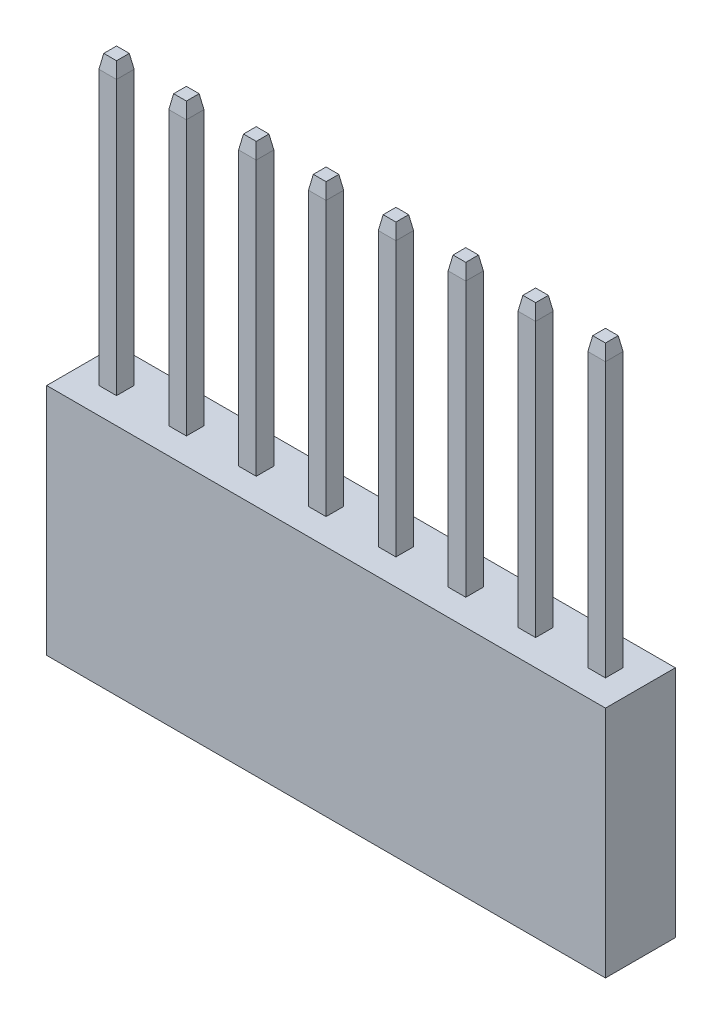
from build123d import *
from OCP.BRepFilletAPI import BRepFilletAPI_MakeChamfer

# Parameters (mm, degrees)
SKETCH1_W                   = 2.54
SKETCH1_H                   = 2.54
BOSS_EXTRUDE1_DEPTH         = 8.5
SKETCH2_W                   = 0.64
SKETCH2_H                   = 0.64
BOSS_EXTRUDE2_DEPTH         = 18.9595482
CHAMFER1_SIZE               = 0.5
CHAMFER1_SIZE2              = 0.08816349
SKETCH3_W                   = 0.64
SKETCH3_H                   = 0.64
CUT_EXTRUDE1_DEPTH          = 6
CHAMFER2_SIZE               = 0.64
LPATTERN1_COUNT             = 8
LPATTERN1_PITCH             = 2.54
CHAMFER1_OF_LPATTERN1_SIZE  = 0.5
CHAMFER1_OF_LPATTERN1_SIZE2 = 0.08816349
CHAMFER2_OF_LPATTERN1_SIZE  = 0.64


with BuildPart() as part:
    # Sketch1 → Boss-Extrude1 (new body)
    with BuildSketch(Plane(origin=(0, 0, 0), x_dir=(1, 0, 0), z_dir=(0, 1, 0))):
        Rectangle(SKETCH1_W, SKETCH1_H)
    boss_extrude1 = extrude(amount=BOSS_EXTRUDE1_DEPTH)

    # Sketch2 → Boss-Extrude2 (add)
    with BuildSketch(Plane(origin=(0, 0, 0), x_dir=(1, 0, 0), z_dir=(0, 1, 0))):
        Rectangle(SKETCH2_W, SKETCH2_H)
    boss_extrude2 = extrude(amount=BOSS_EXTRUDE2_DEPTH)

    # Chamfer1: one chamfer whose edges measure the first distance from different faces: ONE call of the kernel's chamfer builder (chamfer() names one face for all edges)
    chamfer1_edges_1 = [part.edges().sort_by_distance(p)[0] for p in [
        (-0.32, 18.9595482, 0),
    ]]
    chamfer1_side_1 = [part.faces().sort_by_distance(p)[0] for p in [
        (-0.32, 13.7297741, 0),
    ]]
    chamfer1_edges_2 = [part.edges().sort_by_distance(p)[0] for p in [
        (0, 18.9595482, 0.32),
    ]]
    chamfer1_side_2 = [part.faces().sort_by_distance(p)[0] for p in [
        (0, 13.7297741, 0.32),
    ]]
    chamfer1_edges_3 = [part.edges().sort_by_distance(p)[0] for p in [
        (0.32, 18.9595482, 0),
    ]]
    chamfer1_side_3 = [part.faces().sort_by_distance(p)[0] for p in [
        (0.32, 13.7297741, 0),
    ]]
    chamfer1_edges_4 = [part.edges().sort_by_distance(p)[0] for p in [
        (0, 18.9595482, -0.32),
    ]]
    chamfer1_side_4 = [part.faces().sort_by_distance(p)[0] for p in [
        (0, 13.7297741, -0.32),
    ]]
    chamfer1 = BRepFilletAPI_MakeChamfer(part.part.solid().wrapped)
    for e in chamfer1_edges_1:
        chamfer1.Add(CHAMFER1_SIZE, CHAMFER1_SIZE2, e.wrapped, chamfer1_side_1[0].wrapped)  # the first distance lies on this face
    for e in chamfer1_edges_2:
        chamfer1.Add(CHAMFER1_SIZE, CHAMFER1_SIZE2, e.wrapped, chamfer1_side_2[0].wrapped)  # the first distance lies on this face
    for e in chamfer1_edges_3:
        chamfer1.Add(CHAMFER1_SIZE, CHAMFER1_SIZE2, e.wrapped, chamfer1_side_3[0].wrapped)  # the first distance lies on this face
    for e in chamfer1_edges_4:
        chamfer1.Add(CHAMFER1_SIZE, CHAMFER1_SIZE2, e.wrapped, chamfer1_side_4[0].wrapped)  # the first distance lies on this face
    add(Compound.cast(chamfer1.Shape()), mode=Mode.REPLACE)

    # Sketch3 → Cut-Extrude1 (cut)
    with BuildSketch(Plane.XZ):
        Rectangle(SKETCH3_W, SKETCH3_H)
    cut_extrude1 = extrude(amount=-CUT_EXTRUDE1_DEPTH, mode=Mode.SUBTRACT)

    # Chamfer2
    chamfer2_edges = [part.edges().sort_by_distance(p)[0] for p in [
        (-0.32, 0, 0),
        (0, 0, -0.32),
        (0.32, 0, 0),
        (0, 0, 0.32),
    ]]
    chamfer(chamfer2_edges, length=CHAMFER2_SIZE)

    # LPattern1: Boss-Extrude1, Boss-Extrude2, Cut-Extrude1 ×8
    with Locations(*[(-i * LPATTERN1_PITCH, 0, 0) for i in range(1, LPATTERN1_COUNT)]):
        add(boss_extrude1)
        add(boss_extrude2)
        add(cut_extrude1, mode=Mode.SUBTRACT)

    # Chamfer1 of LPattern1: one chamfer whose edges measure the first distance from different faces: ONE call of the kernel's chamfer builder (chamfer() names one face for all edges)
    chamfer1_of_lpattern1_edges_1 = [part.edges().sort_by_distance(p)[0] for p in [
        (-2.86, 18.9595482, 0),
    ]]
    chamfer1_of_lpattern1_side_1 = [part.faces().sort_by_distance(p)[0] for p in [
        (-2.86, 13.7297741, 0),
    ]]
    chamfer1_of_lpattern1_edges_2 = [part.edges().sort_by_distance(p)[0] for p in [
        (-2.54, 18.9595482, 0.32),
    ]]
    chamfer1_of_lpattern1_side_2 = [part.faces().sort_by_distance(p)[0] for p in [
        (-2.54, 13.7297741, 0.32),
    ]]
    chamfer1_of_lpattern1_edges_3 = [part.edges().sort_by_distance(p)[0] for p in [
        (-2.22, 18.9595482, 0),
    ]]
    chamfer1_of_lpattern1_side_3 = [part.faces().sort_by_distance(p)[0] for p in [
        (-2.22, 13.7297741, 0),
    ]]
    chamfer1_of_lpattern1_edges_4 = [part.edges().sort_by_distance(p)[0] for p in [
        (-2.54, 18.9595482, -0.32),
    ]]
    chamfer1_of_lpattern1_side_4 = [part.faces().sort_by_distance(p)[0] for p in [
        (-2.54, 13.7297741, -0.32),
    ]]
    chamfer1_of_lpattern1_edges_5 = [part.edges().sort_by_distance(p)[0] for p in [
        (-5.4, 18.9595482, 0),
    ]]
    chamfer1_of_lpattern1_side_5 = [part.faces().sort_by_distance(p)[0] for p in [
        (-5.4, 13.7297741, 0),
    ]]
    chamfer1_of_lpattern1_edges_6 = [part.edges().sort_by_distance(p)[0] for p in [
        (-5.08, 18.9595482, 0.32),
    ]]
    chamfer1_of_lpattern1_side_6 = [part.faces().sort_by_distance(p)[0] for p in [
        (-5.08, 13.7297741, 0.32),
    ]]
    chamfer1_of_lpattern1_edges_7 = [part.edges().sort_by_distance(p)[0] for p in [
        (-4.76, 18.9595482, 0),
    ]]
    chamfer1_of_lpattern1_side_7 = [part.faces().sort_by_distance(p)[0] for p in [
        (-4.76, 13.7297741, 0),
    ]]
    chamfer1_of_lpattern1_edges_8 = [part.edges().sort_by_distance(p)[0] for p in [
        (-5.08, 18.9595482, -0.32),
    ]]
    chamfer1_of_lpattern1_side_8 = [part.faces().sort_by_distance(p)[0] for p in [
        (-5.08, 13.7297741, -0.32),
    ]]
    chamfer1_of_lpattern1_edges_9 = [part.edges().sort_by_distance(p)[0] for p in [
        (-7.94, 18.9595482, 0),
    ]]
    chamfer1_of_lpattern1_side_9 = [part.faces().sort_by_distance(p)[0] for p in [
        (-7.94, 13.7297741, 0),
    ]]
    chamfer1_of_lpattern1_edges_10 = [part.edges().sort_by_distance(p)[0] for p in [
        (-7.62, 18.9595482, 0.32),
    ]]
    chamfer1_of_lpattern1_side_10 = [part.faces().sort_by_distance(p)[0] for p in [
        (-7.62, 13.7297741, 0.32),
    ]]
    chamfer1_of_lpattern1_edges_11 = [part.edges().sort_by_distance(p)[0] for p in [
        (-7.3, 18.9595482, 0),
    ]]
    chamfer1_of_lpattern1_side_11 = [part.faces().sort_by_distance(p)[0] for p in [
        (-7.3, 13.7297741, 0),
    ]]
    chamfer1_of_lpattern1_edges_12 = [part.edges().sort_by_distance(p)[0] for p in [
        (-7.62, 18.9595482, -0.32),
    ]]
    chamfer1_of_lpattern1_side_12 = [part.faces().sort_by_distance(p)[0] for p in [
        (-7.62, 13.7297741, -0.32),
    ]]
    chamfer1_of_lpattern1_edges_13 = [part.edges().sort_by_distance(p)[0] for p in [
        (-10.48, 18.9595482, 0),
    ]]
    chamfer1_of_lpattern1_side_13 = [part.faces().sort_by_distance(p)[0] for p in [
        (-10.48, 13.7297741, 0),
    ]]
    chamfer1_of_lpattern1_edges_14 = [part.edges().sort_by_distance(p)[0] for p in [
        (-10.16, 18.9595482, 0.32),
    ]]
    chamfer1_of_lpattern1_side_14 = [part.faces().sort_by_distance(p)[0] for p in [
        (-10.16, 13.7297741, 0.32),
    ]]
    chamfer1_of_lpattern1_edges_15 = [part.edges().sort_by_distance(p)[0] for p in [
        (-9.84, 18.9595482, 0),
    ]]
    chamfer1_of_lpattern1_side_15 = [part.faces().sort_by_distance(p)[0] for p in [
        (-9.84, 13.7297741, 0),
    ]]
    chamfer1_of_lpattern1_edges_16 = [part.edges().sort_by_distance(p)[0] for p in [
        (-10.16, 18.9595482, -0.32),
    ]]
    chamfer1_of_lpattern1_side_16 = [part.faces().sort_by_distance(p)[0] for p in [
        (-10.16, 13.7297741, -0.32),
    ]]
    chamfer1_of_lpattern1_edges_17 = [part.edges().sort_by_distance(p)[0] for p in [
        (-13.02, 18.9595482, 0),
    ]]
    chamfer1_of_lpattern1_side_17 = [part.faces().sort_by_distance(p)[0] for p in [
        (-13.02, 13.7297741, 0),
    ]]
    chamfer1_of_lpattern1_edges_18 = [part.edges().sort_by_distance(p)[0] for p in [
        (-12.7, 18.9595482, 0.32),
    ]]
    chamfer1_of_lpattern1_side_18 = [part.faces().sort_by_distance(p)[0] for p in [
        (-12.7, 13.7297741, 0.32),
    ]]
    chamfer1_of_lpattern1_edges_19 = [part.edges().sort_by_distance(p)[0] for p in [
        (-12.38, 18.9595482, 0),
    ]]
    chamfer1_of_lpattern1_side_19 = [part.faces().sort_by_distance(p)[0] for p in [
        (-12.38, 13.7297741, 0),
    ]]
    chamfer1_of_lpattern1_edges_20 = [part.edges().sort_by_distance(p)[0] for p in [
        (-12.7, 18.9595482, -0.32),
    ]]
    chamfer1_of_lpattern1_side_20 = [part.faces().sort_by_distance(p)[0] for p in [
        (-12.7, 13.7297741, -0.32),
    ]]
    chamfer1_of_lpattern1_edges_21 = [part.edges().sort_by_distance(p)[0] for p in [
        (-15.56, 18.9595482, 0),
    ]]
    chamfer1_of_lpattern1_side_21 = [part.faces().sort_by_distance(p)[0] for p in [
        (-15.56, 13.7297741, 0),
    ]]
    chamfer1_of_lpattern1_edges_22 = [part.edges().sort_by_distance(p)[0] for p in [
        (-15.24, 18.9595482, 0.32),
    ]]
    chamfer1_of_lpattern1_side_22 = [part.faces().sort_by_distance(p)[0] for p in [
        (-15.24, 13.7297741, 0.32),
    ]]
    chamfer1_of_lpattern1_edges_23 = [part.edges().sort_by_distance(p)[0] for p in [
        (-14.92, 18.9595482, 0),
    ]]
    chamfer1_of_lpattern1_side_23 = [part.faces().sort_by_distance(p)[0] for p in [
        (-14.92, 13.7297741, 0),
    ]]
    chamfer1_of_lpattern1_edges_24 = [part.edges().sort_by_distance(p)[0] for p in [
        (-15.24, 18.9595482, -0.32),
    ]]
    chamfer1_of_lpattern1_side_24 = [part.faces().sort_by_distance(p)[0] for p in [
        (-15.24, 13.7297741, -0.32),
    ]]
    chamfer1_of_lpattern1_edges_25 = [part.edges().sort_by_distance(p)[0] for p in [
        (-18.1, 18.9595482, 0),
    ]]
    chamfer1_of_lpattern1_side_25 = [part.faces().sort_by_distance(p)[0] for p in [
        (-18.1, 13.7297741, 0),
    ]]
    chamfer1_of_lpattern1_edges_26 = [part.edges().sort_by_distance(p)[0] for p in [
        (-17.78, 18.9595482, 0.32),
    ]]
    chamfer1_of_lpattern1_side_26 = [part.faces().sort_by_distance(p)[0] for p in [
        (-17.78, 13.7297741, 0.32),
    ]]
    chamfer1_of_lpattern1_edges_27 = [part.edges().sort_by_distance(p)[0] for p in [
        (-17.46, 18.9595482, 0),
    ]]
    chamfer1_of_lpattern1_side_27 = [part.faces().sort_by_distance(p)[0] for p in [
        (-17.46, 13.7297741, 0),
    ]]
    chamfer1_of_lpattern1_edges_28 = [part.edges().sort_by_distance(p)[0] for p in [
        (-17.78, 18.9595482, -0.32),
    ]]
    chamfer1_of_lpattern1_side_28 = [part.faces().sort_by_distance(p)[0] for p in [
        (-17.78, 13.7297741, -0.32),
    ]]
    chamfer1_of_lpattern1 = BRepFilletAPI_MakeChamfer(part.part.solid().wrapped)
    for e in chamfer1_of_lpattern1_edges_1:
        chamfer1_of_lpattern1.Add(CHAMFER1_OF_LPATTERN1_SIZE, CHAMFER1_OF_LPATTERN1_SIZE2, e.wrapped, chamfer1_of_lpattern1_side_1[0].wrapped)  # the first distance lies on this face
    for e in chamfer1_of_lpattern1_edges_2:
        chamfer1_of_lpattern1.Add(CHAMFER1_OF_LPATTERN1_SIZE, CHAMFER1_OF_LPATTERN1_SIZE2, e.wrapped, chamfer1_of_lpattern1_side_2[0].wrapped)  # the first distance lies on this face
    for e in chamfer1_of_lpattern1_edges_3:
        chamfer1_of_lpattern1.Add(CHAMFER1_OF_LPATTERN1_SIZE, CHAMFER1_OF_LPATTERN1_SIZE2, e.wrapped, chamfer1_of_lpattern1_side_3[0].wrapped)  # the first distance lies on this face
    for e in chamfer1_of_lpattern1_edges_4:
        chamfer1_of_lpattern1.Add(CHAMFER1_OF_LPATTERN1_SIZE, CHAMFER1_OF_LPATTERN1_SIZE2, e.wrapped, chamfer1_of_lpattern1_side_4[0].wrapped)  # the first distance lies on this face
    for e in chamfer1_of_lpattern1_edges_5:
        chamfer1_of_lpattern1.Add(CHAMFER1_OF_LPATTERN1_SIZE, CHAMFER1_OF_LPATTERN1_SIZE2, e.wrapped, chamfer1_of_lpattern1_side_5[0].wrapped)  # the first distance lies on this face
    for e in chamfer1_of_lpattern1_edges_6:
        chamfer1_of_lpattern1.Add(CHAMFER1_OF_LPATTERN1_SIZE, CHAMFER1_OF_LPATTERN1_SIZE2, e.wrapped, chamfer1_of_lpattern1_side_6[0].wrapped)  # the first distance lies on this face
    for e in chamfer1_of_lpattern1_edges_7:
        chamfer1_of_lpattern1.Add(CHAMFER1_OF_LPATTERN1_SIZE, CHAMFER1_OF_LPATTERN1_SIZE2, e.wrapped, chamfer1_of_lpattern1_side_7[0].wrapped)  # the first distance lies on this face
    for e in chamfer1_of_lpattern1_edges_8:
        chamfer1_of_lpattern1.Add(CHAMFER1_OF_LPATTERN1_SIZE, CHAMFER1_OF_LPATTERN1_SIZE2, e.wrapped, chamfer1_of_lpattern1_side_8[0].wrapped)  # the first distance lies on this face
    for e in chamfer1_of_lpattern1_edges_9:
        chamfer1_of_lpattern1.Add(CHAMFER1_OF_LPATTERN1_SIZE, CHAMFER1_OF_LPATTERN1_SIZE2, e.wrapped, chamfer1_of_lpattern1_side_9[0].wrapped)  # the first distance lies on this face
    for e in chamfer1_of_lpattern1_edges_10:
        chamfer1_of_lpattern1.Add(CHAMFER1_OF_LPATTERN1_SIZE, CHAMFER1_OF_LPATTERN1_SIZE2, e.wrapped, chamfer1_of_lpattern1_side_10[0].wrapped)  # the first distance lies on this face
    for e in chamfer1_of_lpattern1_edges_11:
        chamfer1_of_lpattern1.Add(CHAMFER1_OF_LPATTERN1_SIZE, CHAMFER1_OF_LPATTERN1_SIZE2, e.wrapped, chamfer1_of_lpattern1_side_11[0].wrapped)  # the first distance lies on this face
    for e in chamfer1_of_lpattern1_edges_12:
        chamfer1_of_lpattern1.Add(CHAMFER1_OF_LPATTERN1_SIZE, CHAMFER1_OF_LPATTERN1_SIZE2, e.wrapped, chamfer1_of_lpattern1_side_12[0].wrapped)  # the first distance lies on this face
    for e in chamfer1_of_lpattern1_edges_13:
        chamfer1_of_lpattern1.Add(CHAMFER1_OF_LPATTERN1_SIZE, CHAMFER1_OF_LPATTERN1_SIZE2, e.wrapped, chamfer1_of_lpattern1_side_13[0].wrapped)  # the first distance lies on this face
    for e in chamfer1_of_lpattern1_edges_14:
        chamfer1_of_lpattern1.Add(CHAMFER1_OF_LPATTERN1_SIZE, CHAMFER1_OF_LPATTERN1_SIZE2, e.wrapped, chamfer1_of_lpattern1_side_14[0].wrapped)  # the first distance lies on this face
    for e in chamfer1_of_lpattern1_edges_15:
        chamfer1_of_lpattern1.Add(CHAMFER1_OF_LPATTERN1_SIZE, CHAMFER1_OF_LPATTERN1_SIZE2, e.wrapped, chamfer1_of_lpattern1_side_15[0].wrapped)  # the first distance lies on this face
    for e in chamfer1_of_lpattern1_edges_16:
        chamfer1_of_lpattern1.Add(CHAMFER1_OF_LPATTERN1_SIZE, CHAMFER1_OF_LPATTERN1_SIZE2, e.wrapped, chamfer1_of_lpattern1_side_16[0].wrapped)  # the first distance lies on this face
    for e in chamfer1_of_lpattern1_edges_17:
        chamfer1_of_lpattern1.Add(CHAMFER1_OF_LPATTERN1_SIZE, CHAMFER1_OF_LPATTERN1_SIZE2, e.wrapped, chamfer1_of_lpattern1_side_17[0].wrapped)  # the first distance lies on this face
    for e in chamfer1_of_lpattern1_edges_18:
        chamfer1_of_lpattern1.Add(CHAMFER1_OF_LPATTERN1_SIZE, CHAMFER1_OF_LPATTERN1_SIZE2, e.wrapped, chamfer1_of_lpattern1_side_18[0].wrapped)  # the first distance lies on this face
    for e in chamfer1_of_lpattern1_edges_19:
        chamfer1_of_lpattern1.Add(CHAMFER1_OF_LPATTERN1_SIZE, CHAMFER1_OF_LPATTERN1_SIZE2, e.wrapped, chamfer1_of_lpattern1_side_19[0].wrapped)  # the first distance lies on this face
    for e in chamfer1_of_lpattern1_edges_20:
        chamfer1_of_lpattern1.Add(CHAMFER1_OF_LPATTERN1_SIZE, CHAMFER1_OF_LPATTERN1_SIZE2, e.wrapped, chamfer1_of_lpattern1_side_20[0].wrapped)  # the first distance lies on this face
    for e in chamfer1_of_lpattern1_edges_21:
        chamfer1_of_lpattern1.Add(CHAMFER1_OF_LPATTERN1_SIZE, CHAMFER1_OF_LPATTERN1_SIZE2, e.wrapped, chamfer1_of_lpattern1_side_21[0].wrapped)  # the first distance lies on this face
    for e in chamfer1_of_lpattern1_edges_22:
        chamfer1_of_lpattern1.Add(CHAMFER1_OF_LPATTERN1_SIZE, CHAMFER1_OF_LPATTERN1_SIZE2, e.wrapped, chamfer1_of_lpattern1_side_22[0].wrapped)  # the first distance lies on this face
    for e in chamfer1_of_lpattern1_edges_23:
        chamfer1_of_lpattern1.Add(CHAMFER1_OF_LPATTERN1_SIZE, CHAMFER1_OF_LPATTERN1_SIZE2, e.wrapped, chamfer1_of_lpattern1_side_23[0].wrapped)  # the first distance lies on this face
    for e in chamfer1_of_lpattern1_edges_24:
        chamfer1_of_lpattern1.Add(CHAMFER1_OF_LPATTERN1_SIZE, CHAMFER1_OF_LPATTERN1_SIZE2, e.wrapped, chamfer1_of_lpattern1_side_24[0].wrapped)  # the first distance lies on this face
    for e in chamfer1_of_lpattern1_edges_25:
        chamfer1_of_lpattern1.Add(CHAMFER1_OF_LPATTERN1_SIZE, CHAMFER1_OF_LPATTERN1_SIZE2, e.wrapped, chamfer1_of_lpattern1_side_25[0].wrapped)  # the first distance lies on this face
    for e in chamfer1_of_lpattern1_edges_26:
        chamfer1_of_lpattern1.Add(CHAMFER1_OF_LPATTERN1_SIZE, CHAMFER1_OF_LPATTERN1_SIZE2, e.wrapped, chamfer1_of_lpattern1_side_26[0].wrapped)  # the first distance lies on this face
    for e in chamfer1_of_lpattern1_edges_27:
        chamfer1_of_lpattern1.Add(CHAMFER1_OF_LPATTERN1_SIZE, CHAMFER1_OF_LPATTERN1_SIZE2, e.wrapped, chamfer1_of_lpattern1_side_27[0].wrapped)  # the first distance lies on this face
    for e in chamfer1_of_lpattern1_edges_28:
        chamfer1_of_lpattern1.Add(CHAMFER1_OF_LPATTERN1_SIZE, CHAMFER1_OF_LPATTERN1_SIZE2, e.wrapped, chamfer1_of_lpattern1_side_28[0].wrapped)  # the first distance lies on this face
    add(Compound.cast(chamfer1_of_lpattern1.Shape()), mode=Mode.REPLACE)

    # Chamfer2 of LPattern1
    chamfer2_of_lpattern1_edges = [part.edges().sort_by_distance(p)[0] for p in [
        (-2.86, 0, 0),
        (-2.54, 0, -0.32),
        (-2.22, 0, 0),
        (-2.54, 0, 0.32),
        (-5.4, 0, 0),
        (-5.08, 0, -0.32),
        (-4.76, 0, 0),
        (-5.08, 0, 0.32),
        (-7.94, 0, 0),
        (-7.62, 0, -0.32),
        (-7.3, 0, 0),
        (-7.62, 0, 0.32),
        (-10.48, 0, 0),
        (-10.16, 0, -0.32),
        (-9.84, 0, 0),
        (-10.16, 0, 0.32),
        (-13.02, 0, 0),
        (-12.7, 0, -0.32),
        (-12.38, 0, 0),
        (-12.7, 0, 0.32),
        (-15.56, 0, 0),
        (-15.24, 0, -0.32),
        (-14.92, 0, 0),
        (-15.24, 0, 0.32),
        (-18.1, 0, 0),
        (-17.78, 0, -0.32),
        (-17.46, 0, 0),
        (-17.78, 0, 0.32),
    ]]
    chamfer(chamfer2_of_lpattern1_edges, length=CHAMFER2_OF_LPATTERN1_SIZE)


solid = part.part
